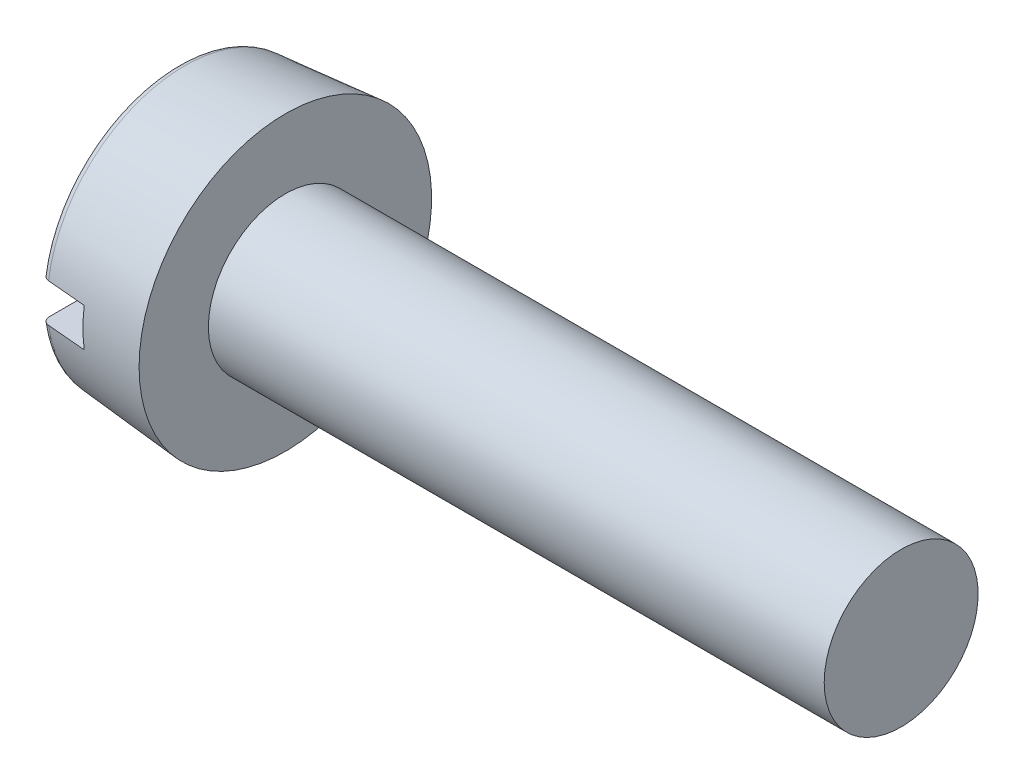
from build123d import *

# Parameters (mm, degrees)
FILLET2_R  = 0.1
SKETCH2_W  = 3.8
SKETCH2_H  = 0.5
SLOT_DEPTH = 0.6


with BuildPart() as part:
    # BodySke → Base-Revolve (revolve)
    with BuildSketch(Plane.XY):
        Polygon((1.4, 1), (1.4, 1.9), (0, 1.777515871), (0, 0), (9.4, 0), (9.4, 1), align=None)
    revolve(axis=Axis((-25.4, 0, 0), (1, 0, 0)))

    # Fillet2
    fillet2_edges = [part.edges().sort_by_distance(p)[0] for p in [
        (0, -1.777515871, 0),
    ]]
    fillet(fillet2_edges, radius=FILLET2_R)

    # Sketch2 → Slot (cut)
    with BuildSketch(Plane(origin=(0, 0, 0), x_dir=(0, 0, -1), z_dir=(1, 0, 0))):
        Rectangle(SKETCH2_W, SKETCH2_H)
    extrude(amount=SLOT_DEPTH, mode=Mode.SUBTRACT)


solid = part.part
